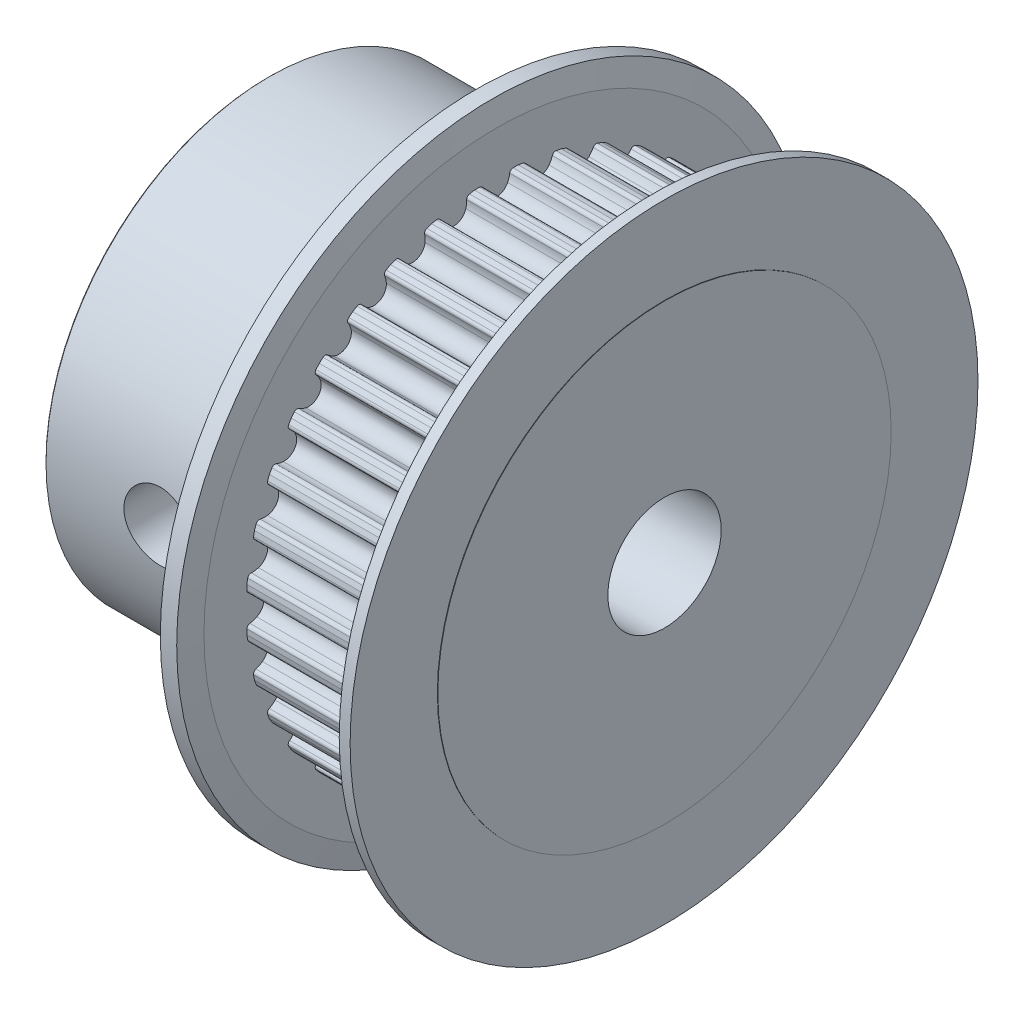
from build123d import *

# Parameters (mm, degrees)
SKETCH_2_R               = 2.5
BORE_DEPTH               = 18.5
TEETH_DEPTH              = 6.5
SKETCH_4_R               = 1.5
FIX_2_DEPTH              = 14.92317856
PATTERN_CIRCULAR_3_COUNT = 36


with BuildPart() as part:
    # Sketch 1 → Body (revolve)
    with BuildSketch(Plane.XY):
        Polygon((0, 9.786049427), (0, 0), (17.5, 0), (17.5, 10), (17.48, 10), (17.48, 13.85), (16.99969124, 13.85), (16.58, 12.896693753), (16.58, 11.05), (10.08, 11.05), (10.08, 12.896693753), (9.903188012, 13.92317856), (9.18, 13.92317856), (9.18, 9.85), (0.064328516, 9.85), align=None)
    revolve(axis=Axis((0, 0, 0), (1, 0, 0)))

    # Sketch 2 → Bore (cut, through all)
    with BuildSketch(Plane(origin=(17.5, 0, 0), x_dir=(0, 0, -1), z_dir=(1, 0, 0))):
        Circle(SKETCH_2_R)
    extrude(amount=-BORE_DEPTH, mode=Mode.SUBTRACT)

    # Sketch 3 → Teeth (cut)
    with BuildSketch(Plane(origin=(10.08, 0, 0), x_dir=(0, 0, -1), z_dir=(1, 0, 0))):
        with BuildLine():
            Line((0.739871708, 11.004279791), (1.004154512, 11.004279791))
            Line((1.004154512, 11.004279791), (1.082252627, 11.476297828))
            Line((1.082252627, 11.476297828), (-1.096426889, 11.476297828))
            Line((-1.096426889, 11.476297828), (-1.000303717, 11.004279791))
            Line((-1.000303717, 11.004279791), (-0.740479142, 11.004279791))
            ThreePointArc((-0.740479142, 11.004279791), (-0.641572071, 10.967051203), (-0.591760608, 10.873845008))
            ThreePointArc((-0.591760608, 10.873845008), (-0.557915431, 10.716217637), (-0.499180121, 10.566077544))
            ThreePointArc((-0.499180121, 10.566077544), (-0.000303717, 10.254279791), (0.498572688, 10.566077544))
            ThreePointArc((0.498572688, 10.566077544), (0.557307998, 10.716217637), (0.591153175, 10.873845008))
            ThreePointArc((0.591153175, 10.873845008), (0.640964637, 10.967051203), (0.739871708, 11.004279791))
        make_face()
    teeth = extrude(amount=TEETH_DEPTH, mode=Mode.SUBTRACT)

    # Sketch 4 → Fix 2 (cut, through all)
    with BuildSketch(Plane.XY):
        with Locations((5, 0)):
            Circle(SKETCH_4_R)
    extrude(amount=FIX_2_DEPTH, mode=Mode.SUBTRACT)

    # Pattern Circular 3: Teeth ×36 about axis
    pattern_circular_3_axis = Axis((0, 0, 0), (1, 0, 0))
    for i in range(1, PATTERN_CIRCULAR_3_COUNT):
        add(teeth.rotate(pattern_circular_3_axis, i * 360 / PATTERN_CIRCULAR_3_COUNT), mode=Mode.SUBTRACT)


solid = part.part
